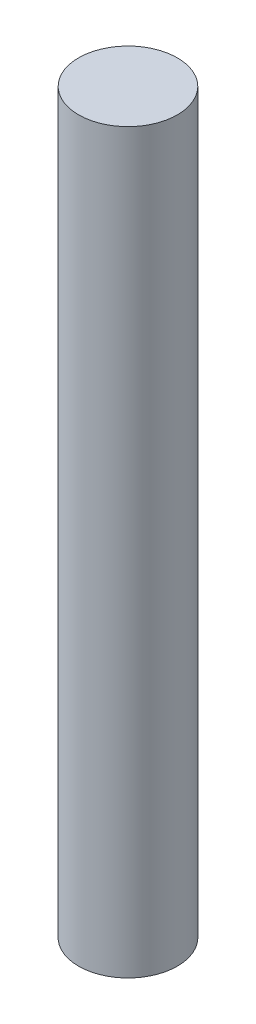
from build123d import *

# Parameters (mm, degrees)
SKETCH1_R           = 4.69
BOSS_EXTRUDE1_DEPTH = 70


with BuildPart() as part:
    # Sketch1 → Boss-Extrude1 (new body)
    with BuildSketch(Plane(origin=(0, 0, 0), x_dir=(1, 0, 0), z_dir=(0, 1, 0))):
        Circle(SKETCH1_R)
    extrude(amount=BOSS_EXTRUDE1_DEPTH)


solid = part.part
